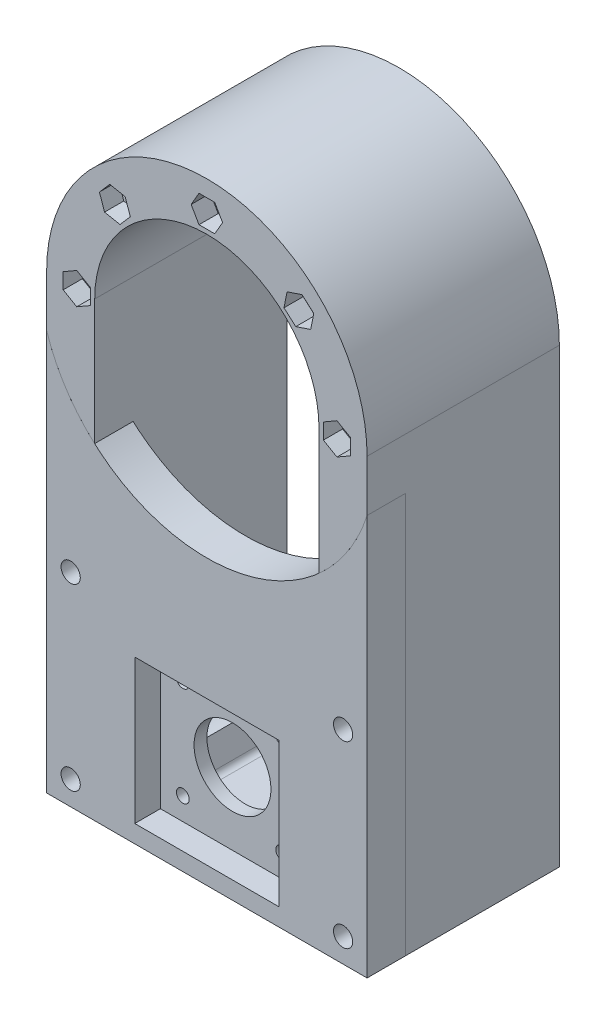
from build123d import *

# Parameters (mm, degrees)
SALIENTE_EXTRUIR1_DEPTH = 60
CROQUIS2_R              = 3
CORTAR_EXTRUIR1_DEPTH   = 60
CORTAR_EXTRUIR2_DEPTH   = 6
CORTAR_EXTRUIR3_DEPTH   = 12
CROQUIS5_R              = 3
CORTAR_EXTRUIR4_DEPTH   = 48
CORTAR_EXTRUIR5_DEPTH   = 6
CORTAR_EXTRUIR6_DEPTH   = 6
CORTAR_EXTRUIR7_DEPTH   = 48
CROQUIS9_R              = 3
SALIENTE_EXTRUIR2_DEPTH = 12
CROQUIS10_R             = 12
CORTAR_EXTRUIR8_DEPTH   = 12
CROQUIS11_W             = 45
CROQUIS11_H             = 45
CORTAR_EXTRUIR9_DEPTH   = 8
CROQUIS12_R             = 2
CORTAR_EXTRUIR10_DEPTH  = 53


with BuildPart() as part:
    # Croquis1 → Saliente-Extruir1 (new body)
    with BuildSketch(Plane.XY):
        with BuildLine():
            Line((-50, 0), (-50, -141))
            Line((-50, -141), (50, -141))
            Line((50, -141), (50, 0))
            ThreePointArc((50, 0), (0, 50), (-50, 0))
        make_face()
        with BuildLine():
            Line((-35, 0), (-35, -116))
            ThreePointArc((-35, -116), (-32.071067812, -123.071067812), (-25, -126))
            Line((-25, -126), (25, -126))
            ThreePointArc((25, -126), (32.071067812, -123.071067812), (35, -116))
            Line((35, -116), (35, 0))
            ThreePointArc((35, 0), (0, 35), (-35, 0))
        make_face(mode=Mode.SUBTRACT)
    extrude(amount=SALIENTE_EXTRUIR1_DEPTH)

    # Croquis2 → Cortar-Extruir1 (cut)
    with BuildSketch(Plane.XY.offset(60)):
        with Locations((0, 40.605)):
            Circle(CROQUIS2_R)
        with Locations((28.71207085, 28.71207085)):
            Circle(CROQUIS2_R)
        with Locations((40.605, 0)):
            Circle(CROQUIS2_R)
        with Locations((-40.605, 0)):
            Circle(CROQUIS2_R)
        with Locations((-28.71207085, 28.71207085)):
            Circle(CROQUIS2_R)
    extrude(amount=-CORTAR_EXTRUIR1_DEPTH, mode=Mode.SUBTRACT)

    # Croquis3 → Cortar-Extruir2 (cut)
    with BuildSketch(Plane.XY.offset(60)):
        Polygon((4.907477288, 40.605), (2.453738644, 44.855), (-2.453738644, 44.855), (-4.907477288, 40.605), (-2.453738644, 36.355), (2.453738644, 36.355), align=None)
        Polygon((33.365133185, 30.271668311), (29.687950997, 33.521539768), (25.034888662, 31.961942307), (24.059008515, 27.152473389), (27.736190704, 23.902601932), (32.389253039, 25.462199393), align=None)
        Polygon((40.605, -4.907477288), (44.855, -2.453738644), (44.855, 2.453738644), (40.605, 4.907477288), (36.355, 2.453738644), (36.355, -2.453738644), align=None)
        Polygon((-33.528922476, 29.650832668), (-31.933488245, 25.009935885), (-27.11663662, 24.071174067), (-23.895219225, 27.773309032), (-25.490653455, 32.414205815), (-30.30750508, 33.352967633), align=None)
        Polygon((-40.605, 4.907477288), (-44.855, 2.453738644), (-44.855, -2.453738644), (-40.605, -4.907477288), (-36.355, -2.453738644), (-36.355, 2.453738644), align=None)
    extrude(amount=-CORTAR_EXTRUIR2_DEPTH, mode=Mode.SUBTRACT)

    # Croquis4 → Cortar-Extruir3 (cut)
    with BuildSketch(Plane.XY.offset(60)):
        with BuildLine():
            Line((-50, -16.007810594), (-50, -141))
            Line((-50, -141), (50, -141))
            Line((50, -141), (50, -16.007810594))
            ThreePointArc((50, -16.007810594), (0, -52.5), (-50, -16.007810594))
        make_face()
    extrude(amount=-CORTAR_EXTRUIR3_DEPTH, mode=Mode.SUBTRACT)

    # Croquis5 → Cortar-Extruir4 (cut)
    with BuildSketch(Plane.XY.offset(48)):
        with Locations((-42.5, -77.565594803)):
            Circle(CROQUIS5_R)
        with Locations((-42.5, -133.5)):
            Circle(CROQUIS5_R)
        with Locations((42.5, -77.565594803)):
            Circle(CROQUIS5_R)
        with Locations((42.5, -133.5)):
            Circle(CROQUIS5_R)
    extrude(amount=-CORTAR_EXTRUIR4_DEPTH, mode=Mode.SUBTRACT)

    # Croquis6 → Cortar-Extruir5 (cut)
    with BuildSketch(Plane.XY.offset(48)):
        Polygon((-42.421317924, -82.472441292), (-38.21120525, -79.950877371), (-38.289887326, -75.044030882), (-42.578682076, -72.658748314), (-46.78879475, -75.180312235), (-46.710112674, -80.087158724), align=None)
        Polygon((42.5, -82.473072091), (46.75, -80.019333447), (46.75, -75.111856159), (42.5, -72.658117515), (38.25, -75.111856159), (38.25, -80.019333447), align=None)
        Polygon((-40.063566251, -129.240055878), (-44.971002953, -129.260014418), (-47.407436703, -133.519958539), (-44.936433749, -137.759944122), (-40.028997047, -137.739985582), (-37.592563297, -133.480041461), align=None)
        Polygon((44.895973885, -129.217168871), (39.988946385, -129.283610185), (37.5929725, -133.566441313), (40.104026115, -137.782831129), (45.011053615, -137.716389815), (47.4070275, -133.433558687), align=None)
    extrude(amount=-CORTAR_EXTRUIR5_DEPTH, mode=Mode.SUBTRACT)

    # Croquis7 → Cortar-Extruir6 (cut)
    with BuildSketch(Plane(origin=(0, 0, 0), x_dir=(-1, 0, 0), z_dir=(0, 0, -1))):
        Polygon((2.357863822, 44.908929778), (-2.548380612, 44.798934857), (-4.906244434, 40.49500508), (-2.357863822, 36.301070222), (2.548380612, 36.411065143), (4.906244434, 40.71499492), align=None)
        Polygon((-40.614441302, 4.907468206), (-44.859712786, 2.445557696), (-44.850271484, -2.461910511), (-40.595558698, -4.907468206), (-36.350287214, -2.445557696), (-36.359728516, 2.461910511), align=None)
        Polygon((44.882492584, -2.405491744), (44.826963251, 2.50167137), (40.549470667, 4.907163114), (36.327507416, 2.405491744), (36.383036749, -2.50167137), (40.660529333, -4.907163114), align=None)
        Polygon((-42.131373877, -72.671981811), (-46.553680106, -74.79954872), (-46.922306229, -79.693161712), (-42.868626123, -82.459207795), (-38.446319894, -80.331640886), (-38.077693771, -75.438027894), align=None)
        Polygon((42.084370643, -72.675749655), (38.057455203, -75.480617811), (38.47308456, -80.370462959), (42.915629357, -82.455439951), (46.942544797, -79.650571795), (46.52691544, -74.760726647), align=None)
        Polygon((47.407477288, -133.5), (44.953738644, -129.25), (40.046261356, -129.25), (37.592522712, -133.5), (40.046261356, -137.75), (44.953738644, -137.75), align=None)
        Polygon((-44.636850652, -137.917827818), (-39.742474206, -137.559480857), (-37.605623555, -133.14165304), (-40.363149348, -129.082172182), (-45.257525794, -129.440519143), (-47.394376445, -133.85834696), align=None)
    extrude(amount=-CORTAR_EXTRUIR6_DEPTH, mode=Mode.SUBTRACT)

    # Croquis8 → Cortar-Extruir7 (cut)
    with BuildSketch(Plane.XY.offset(48)):
        with BuildLine():
            Line((-22.892371948, -134.008986599), (-25, -126))
            Line((-25, -126), (25, -126))
            Line((25, -126), (22.892371948, -134.008986599))
            ThreePointArc((22.892371948, -134.008986599), (22.17929347, -135.083978093), (20.958222873, -135.5))
            Line((20.958222873, -135.5), (-20.958222873, -135.5))
            ThreePointArc((-20.958222873, -135.5), (-22.17929347, -135.083978093), (-22.892371948, -134.008986599))
        make_face()
    extrude(amount=-CORTAR_EXTRUIR7_DEPTH, mode=Mode.SUBTRACT)


with BuildPart() as body_2:
    # Croquis9 → Saliente-Extruir2 (new body)
    with BuildSketch(Plane.XY.offset(48)):
        with BuildLine():
            ThreePointArc((-20.958222873, -135.5), (-22.17929347, -135.083978093), (-22.892371948, -134.008986599))
            Line((-22.892371948, -134.008986599), (-25, -126))
            ThreePointArc((-25, -126), (-32.071067812, -123.071067812), (-35, -116))
            Line((-35, -116), (-35, -39.131189606))
            ThreePointArc((-35, -39.131189606), (-44.044553173, -28.571442661), (-50, -16.007810594))
            Line((-50, -16.007810594), (-50, -141))
            Line((-50, -141), (50, -141))
            Line((50, -141), (50, -16.007810594))
            ThreePointArc((50, -16.007810594), (44.044553173, -28.571442661), (35, -39.131189606))
            Line((35, -39.131189606), (35, -116))
            ThreePointArc((35, -116), (32.071067812, -123.071067812), (25, -126))
            Line((25, -126), (22.892371948, -134.008986599))
            ThreePointArc((22.892371948, -134.008986599), (22.17929347, -135.083978093), (20.958222873, -135.5))
            Line((20.958222873, -135.5), (-20.958222873, -135.5))
        make_face()
        Polygon((39.988946385, -129.283610185), (44.895973885, -129.217168871), (47.4070275, -133.433558687), (45.011053615, -137.716389815), (40.104026115, -137.782831129), (37.5929725, -133.566441313), align=None, mode=Mode.SUBTRACT)
        Polygon((46.75, -80.019333447), (42.5, -82.473072091), (38.25, -80.019333447), (38.25, -75.111856159), (42.5, -72.658117515), (46.75, -75.111856159), align=None, mode=Mode.SUBTRACT)
        Polygon((-38.21120525, -79.950877371), (-42.421317924, -82.472441292), (-46.710112674, -80.087158724), (-46.78879475, -75.180312235), (-42.578682076, -72.658748314), (-38.289887326, -75.044030882), align=None, mode=Mode.SUBTRACT)
        Polygon((-44.971002953, -129.260014418), (-40.063566251, -129.240055878), (-37.592563297, -133.480041461), (-40.028997047, -137.739985582), (-44.936433749, -137.759944122), (-47.407436703, -133.519958539), align=None, mode=Mode.SUBTRACT)
        Polygon((-42.421317924, -82.472441292), (-46.710112674, -80.087158724), (-46.78879475, -75.180312235), (-42.578682076, -72.658748314), (-38.289887326, -75.044030882), (-38.21120525, -79.950877371), align=None)
        with Locations((-42.5, -77.565594803)):
            Circle(CROQUIS9_R, mode=Mode.SUBTRACT)
        Polygon((-40.063566251, -129.240055878), (-37.592563297, -133.480041461), (-40.028997047, -137.739985582), (-44.936433749, -137.759944122), (-47.407436703, -133.519958539), (-44.971002953, -129.260014418), align=None)
        with Locations((-42.5, -133.5)):
            Circle(CROQUIS9_R, mode=Mode.SUBTRACT)
        Polygon((44.895973885, -129.217168871), (47.4070275, -133.433558687), (45.011053615, -137.716389815), (40.104026115, -137.782831129), (37.5929725, -133.566441313), (39.988946385, -129.283610185), align=None)
        with Locations((42.5, -133.5)):
            Circle(CROQUIS9_R, mode=Mode.SUBTRACT)
        Polygon((42.5, -82.473072091), (38.25, -80.019333447), (38.25, -75.111856159), (42.5, -72.658117515), (46.75, -75.111856159), (46.75, -80.019333447), align=None)
        with Locations((42.5, -77.565594803)):
            Circle(CROQUIS9_R, mode=Mode.SUBTRACT)
        with BuildLine():
            Line((-25, -126), (-22.892371948, -134.008986599))
            ThreePointArc((-22.892371948, -134.008986599), (-22.17929347, -135.083978093), (-20.958222873, -135.5))
            Line((-20.958222873, -135.5), (20.958222873, -135.5))
            ThreePointArc((20.958222873, -135.5), (22.17929347, -135.083978093), (22.892371948, -134.008986599))
            Line((22.892371948, -134.008986599), (25, -126))
            ThreePointArc((25, -126), (32.071067812, -123.071067812), (35, -116))
            Line((35, -116), (35, -39.131189606))
            ThreePointArc((35, -39.131189606), (0, -52.5), (-35, -39.131189606))
            Line((-35, -39.131189606), (-35, -116))
            ThreePointArc((-35, -116), (-32.071067812, -123.071067812), (-25, -126))
        make_face()
    extrude(amount=SALIENTE_EXTRUIR2_DEPTH)

    # Croquis10 → Cortar-Extruir8 (cut)
    with BuildSketch(Plane.XY.offset(60)):
        with Locations((0, -113)):
            Circle(CROQUIS10_R)
    extrude(amount=-CORTAR_EXTRUIR8_DEPTH, mode=Mode.SUBTRACT)

    # Croquis11 → Cortar-Extruir9 (cut)
    with BuildSketch(Plane.XY.offset(60)):
        with Locations((0, -113)):
            Rectangle(CROQUIS11_W, CROQUIS11_H)
    extrude(amount=-CORTAR_EXTRUIR9_DEPTH, mode=Mode.SUBTRACT)

    # Croquis12 → Cortar-Extruir10 (cut, through all)
    with BuildSketch(Plane.XY.offset(52)):
        with Locations((-15.5, -97.5)):
            Circle(CROQUIS12_R)
        with Locations((15.5, -97.5)):
            Circle(CROQUIS12_R)
        with Locations((15.5, -128.5)):
            Circle(CROQUIS12_R)
        with Locations((-15.5, -128.5)):
            Circle(CROQUIS12_R)
    extrude(amount=-CORTAR_EXTRUIR10_DEPTH, mode=Mode.SUBTRACT)


solid = Compound([part.part, body_2.part])
